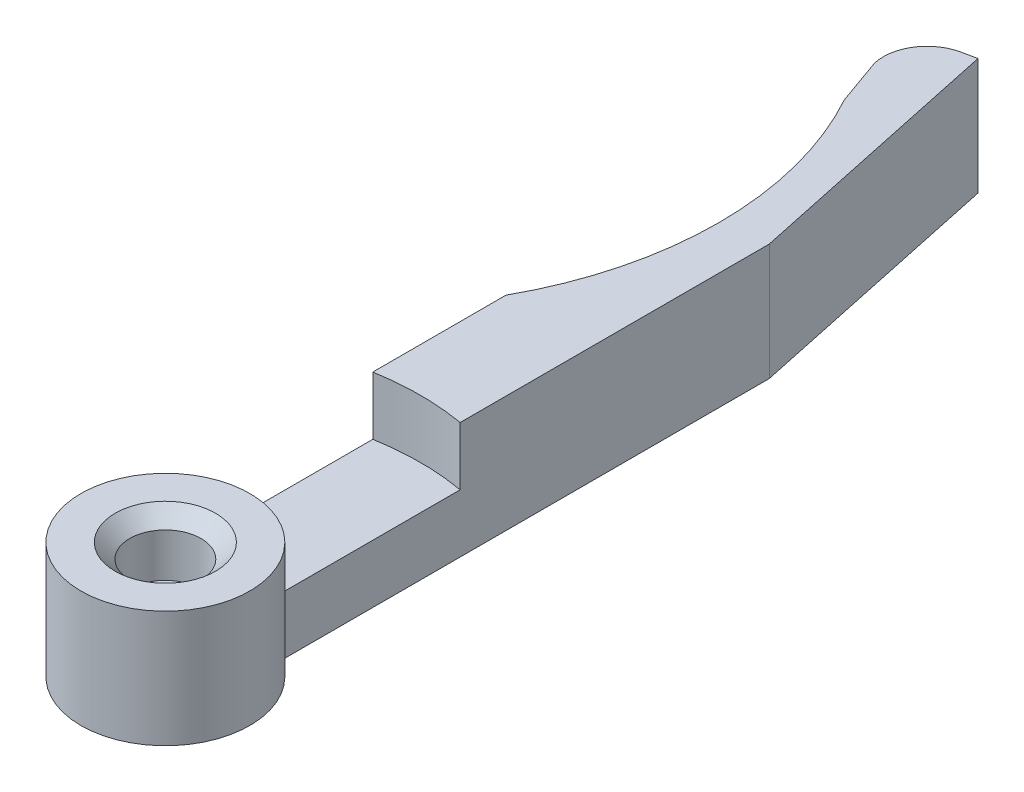
from build123d import *

# Parameters (mm, degrees)
BOSS_EXTRU_1_DEPTH      = 8
ESQUISSE2_R             = 2.45
ENL_V_MAT_EXTRU_1_DEPTH = 4
ENL_V_MAT_EXTRU_2_REACH = 6
ESQUISSE3_R             = 1.75
ESQUISSE4_R             = 3.75
ENL_V_MAT_EXTRU_3_DEPTH = 2.5
ENL_V_MAT_EXTRU_4_DEPTH = 4
CHANFREIN1_SIZE         = 1


with BuildPart() as part:
    # Esquisse1 → Boss.-Extru.1 (new body)
    with BuildSketch(Plane(origin=(0, 0, 0), x_dir=(1, 0, 0), z_dir=(0, 1, 0))):
        with BuildLine():
            Line((-3, 26.381049961), (-3, 4.963869458))
            ThreePointArc((-3, 4.963869458), (0, -5.8), (3, 4.963869458))
            Line((3, 4.963869458), (3, 38.463869458))
            Line((3, 38.463869458), (-0.867157449, 56.657414832))
            Line((-0.867157449, 56.657414832), (-1.84530505, 56.449503141))
            ThreePointArc((-1.84530505, 56.449503141), (-3.756758837, 55.119060789), (-4.140414176, 52.821988519))
            Line((-4.140414176, 52.821988519), (-3, 49.618950039))
            ThreePointArc((-3, 49.618950039), (0, 38), (-3, 26.381049961))
        make_face()
    extrude(amount=BOSS_EXTRU_1_DEPTH)

    # Esquisse2 → Enlèv. mat.-Extru.1 (cut)
    with BuildSketch(Plane(origin=(0, 8, 0), x_dir=(1, 0, 0), z_dir=(0, 1, 0))):
        Circle(ESQUISSE2_R)
    extrude(amount=-ENL_V_MAT_EXTRU_1_DEPTH, mode=Mode.SUBTRACT)

    # Esquisse3 → Enlèv. mat.-Extru.2 (cut, up to next)
    with BuildSketch(Plane(origin=(0, 4, 0), x_dir=(1, 0, 0), z_dir=(0, 1, 0)), mode=Mode.PRIVATE) as enl_v_mat_extru_2_sk1:
        Circle(ESQUISSE3_R)
    enl_v_mat_extru_2_tool1 = extrude(enl_v_mat_extru_2_sk1.sketch, amount=-ENL_V_MAT_EXTRU_2_REACH, mode=Mode.PRIVATE) & part.part
    add(enl_v_mat_extru_2_tool1.solids().sort_by_distance((0, 4, 0))[0], mode=Mode.SUBTRACT)

    # Esquisse4 → Enlèv. mat.-Extru.3 (cut)
    with BuildSketch(Plane.XZ):
        Circle(ESQUISSE4_R)
    extrude(amount=-ENL_V_MAT_EXTRU_3_DEPTH, mode=Mode.SUBTRACT)

    # Esquisse5 → Enlèv. mat.-Extru.4 (cut)
    with BuildSketch(Plane(origin=(0, 8, 0), x_dir=(1, 0, 0), z_dir=(0, 1, 0))):
        with BuildLine():
            Line((-3, 4.963869458), (-3, 17.24093965))
            ThreePointArc((-3, 17.24093965), (0, 17.5), (3, 17.24093965))
            Line((3, 17.24093965), (3, 4.963869458))
            ThreePointArc((3, 4.963869458), (0, 5.8), (-3, 4.963869458))
        make_face()
    extrude(amount=-ENL_V_MAT_EXTRU_4_DEPTH, mode=Mode.SUBTRACT)

    # Chanfrein1
    chanfrein1_edges = [part.edges().sort_by_distance(p)[0] for p in [
        (-2.45, 8, 0),
    ]]
    chamfer(chanfrein1_edges, length=CHANFREIN1_SIZE)


solid = part.part
